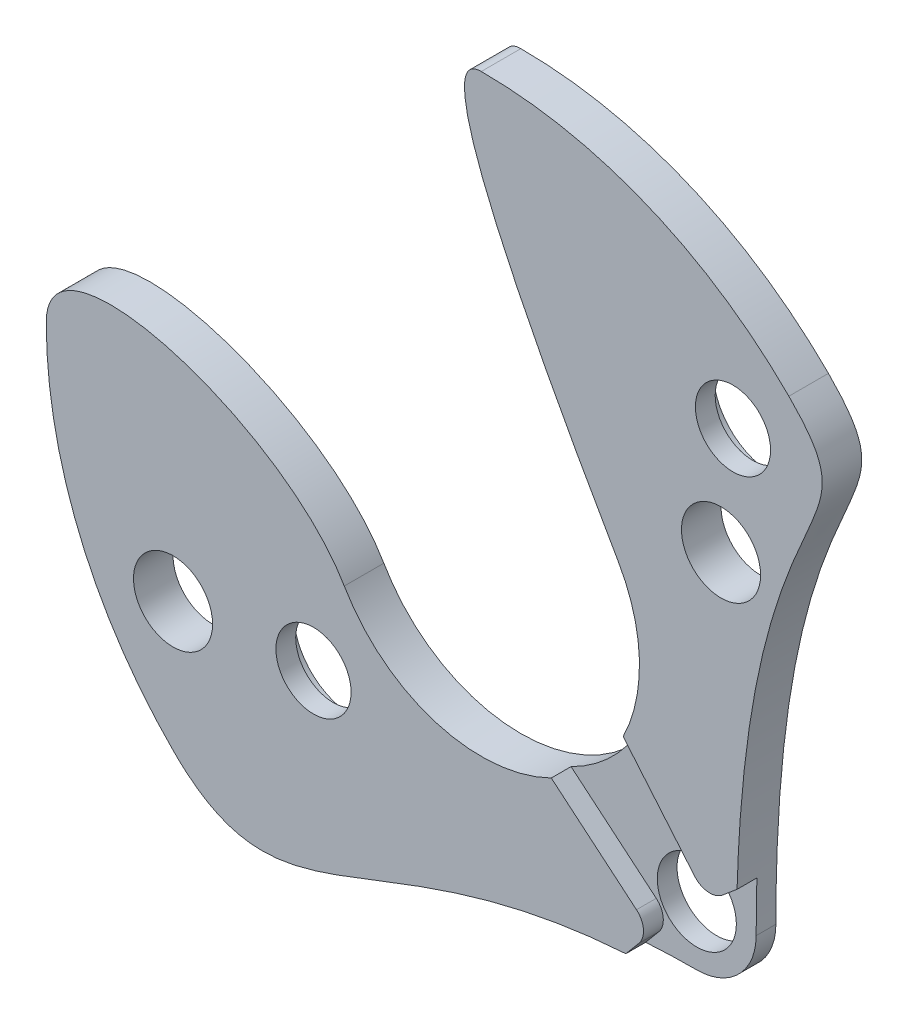
from build123d import *

# Parameters (mm, degrees)
CROQUIS1_R                   = 0.5
SALIENTE_EXTRUIR1_DEPTH      = 0.5
CROQUIS3_R                   = 0.75
CORTAR_EXTRUIR1_DEPTH        = 0.25
CORTAR_EXTRUIR2_DEPTH        = 0.25
TALADRO_ROSCADO_M1_2X0_251_D = 0.95


with BuildPart() as part:
    # Croquis1 → Saliente-Extruir1 (new body)
    with BuildSketch(Plane.XY):
        with BuildLine():
            add(Edge.make_bspline(
                [(3.889087297, 3.889087297), (5.132893433, 2.64528116), (3.224873734, 3.014627212), (3.224873734, -2.474873734)],
                knots=[0, 0, 0, 0, 0.763896924, 0.763896924, 0.763896924, 0.763896924], degree=3))
            ThreePointArc((3.889087297, 3.889087297), (2.104758878, 5.081337429), (0, 5.5))
            add(Edge.make_bspline(
                [(1.732050808, 1), (0.948721344, 2.35676643), (-0.820788378, 5.5), (0, 5.5)],
                knots=[0, 0, 0, 0, 1, 1, 1, 1], degree=3))
            ThreePointArc((1.732050808, 1), (1, -1.732050808), (-1.732050808, -1))
            add(Edge.make_bspline(
                [(-1.732050808, -1), (-2.515380271, 0.35676643), (-5.5, 1.262116296), (-5.5, 0)],
                knots=[0, 0, 0, 0, 1, 1, 1, 1], degree=3))
            ThreePointArc((-5.5, 0), (-5.081337429, -2.104758878), (-3.889087297, -3.889087297))
            add(Edge.make_bspline(
                [(2.474873734, -3.224873734), (-1.35865781, -3.224873734), (-2.388951019, -5.389223574), (-3.889087297, -3.889087297)],
                knots=[0, 0, 0, 0, 1, 1, 1, 1], degree=3))
            ThreePointArc((2.474873734, -3.224873734), (3.00520382, -3.00520382), (3.224873734, -2.474873734))
        make_face()
        with Locations((-3.897114317, -2.25)):
            Circle(CROQUIS1_R, mode=Mode.SUBTRACT)
        with Locations((2.474873734, -2.474873734)):
            Circle(CROQUIS1_R, mode=Mode.SUBTRACT)
        with Locations((3.031088913, 1.75)):
            Circle(CROQUIS1_R, mode=Mode.SUBTRACT)
    extrude(amount=SALIENTE_EXTRUIR1_DEPTH)

    # Croquis3 → Cortar-Extruir1 (cut)
    with BuildSketch(Plane(origin=(0, 0, 0), x_dir=(-1, 0, 0), z_dir=(0, 0, -1))):
        with Locations((-3.181980515, 3.181980515)):
            Circle(CROQUIS3_R)
        with Locations((2.121320344, -2.121320344)):
            Circle(CROQUIS3_R)
    extrude(amount=-CORTAR_EXTRUIR1_DEPTH, mode=Mode.SUBTRACT)

    # Croquis4 → Cortar-Extruir2 (cut)
    with BuildSketch(Plane.XY.offset(0.5)):
        with BuildLine():
            Line((2.697199053, -1.961968819), (1.793528827, -0.88501658))
            ThreePointArc((1.793528827, -0.88501658), (1.414213562, -1.414213562), (0.88501658, -1.793528827))
            Line((0.88501658, -1.793528827), (1.961968819, -2.697199053))
            ThreePointArc((1.961968819, -2.697199053), (2.050320591, -2.866921228), (1.992783027, -3.049407066))
            Line((1.992783027, -3.049407066), (1.827745002, -3.246091726))
            add(Edge.make_bspline(
                [(2.474873734, -3.224873734), (2.249714916, -3.224873734), (2.034226396, -3.232340066), (1.827745002, -3.246091726)],
                knots=[0, 0, 0, 0, 0.058734046, 0.058734046, 0.058734046, 0.058734046], degree=3))
            ThreePointArc((2.474873734, -3.224873734), (3.00520382, -3.00520382), (3.224873734, -2.474873734))
            add(Edge.make_bspline(
                [(3.233875287, -1.837995811), (3.227985327, -2.041061917), (3.224873734, -2.253190531), (3.224873734, -2.474873734)],
                knots=[0.733048379, 0.733048379, 0.733048379, 0.733048379, 0.763896924, 0.763896924, 0.763896924, 0.763896924], degree=3))
            Line((3.233875287, -1.837995811), (3.049407066, -1.992783027))
            ThreePointArc((3.049407066, -1.992783027), (2.866921228, -2.050320591), (2.697199053, -1.961968819))
        make_face()
    extrude(amount=-CORTAR_EXTRUIR2_DEPTH, mode=Mode.SUBTRACT)

    # Taladro roscado M1.2x0.251 (through all)
    with Locations(Plane(origin=(0, 0, 0.25), x_dir=(-1, 0, 0), z_dir=(0, 0, -1))):
        with Locations((2.121320344, -2.121320344), (-3.181980515, 3.181980515)):
            Hole(TALADRO_ROSCADO_M1_2X0_251_D / 2)


solid = part.part
